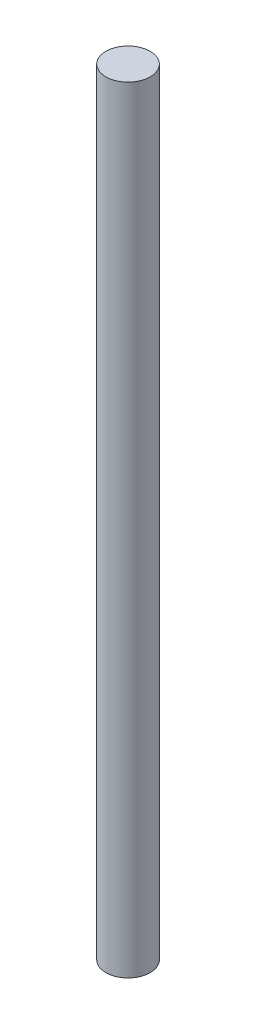
from build123d import *

# Parameters (mm, degrees)
SKETCH1_W = 2
SKETCH1_H = 70


with BuildPart() as part:
    # Sketch1 → Revolve1 (revolve)
    with BuildSketch(Plane.XY):
        with Locations((1, 0)):
            Rectangle(SKETCH1_W, SKETCH1_H)
    revolve(axis=Axis((0, 0, 0), (0, 1, 0)))


solid = part.part
